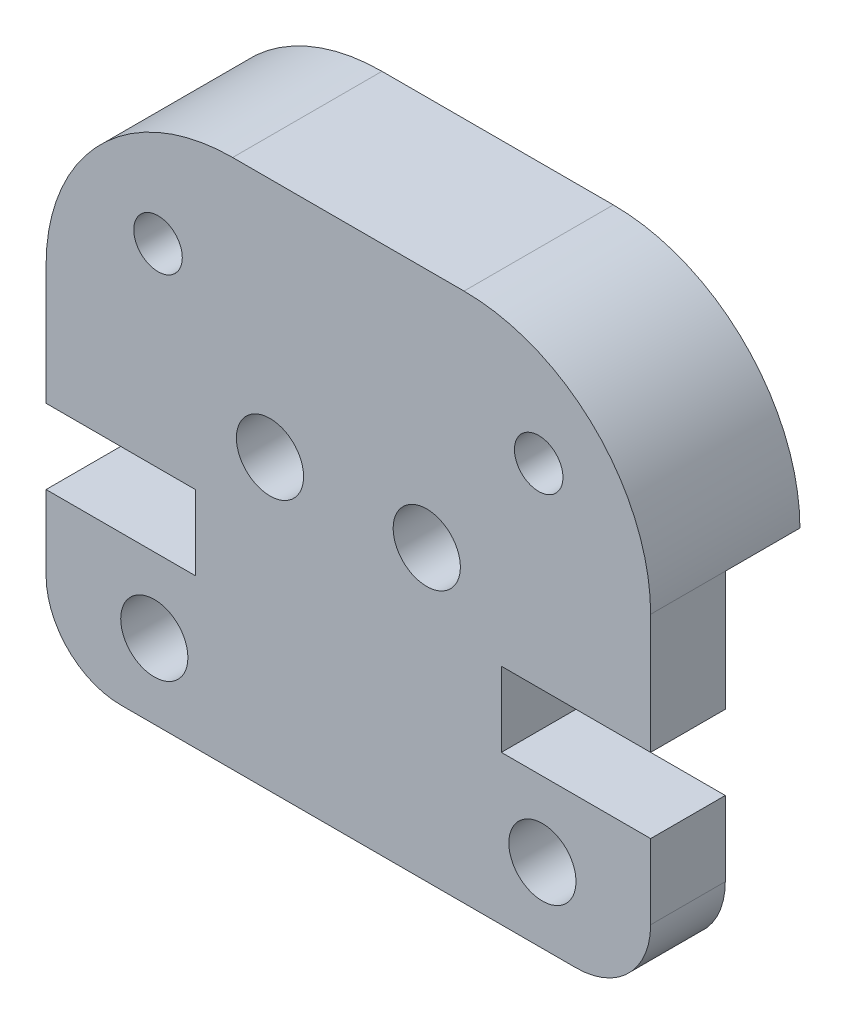
from build123d import *

# Parameters (mm, degrees)
SKETCH1_R           = 0.9
SKETCH1_R_2         = 0.65
BOSS_EXTRUDE1_DEPTH = 4
SKETCH2_W           = 16.2
SKETCH2_H           = 9.205
CUT_EXTRUDE1_DEPTH  = 2


with BuildPart() as part:
    # Sketch1 → Boss-Extrude1 (new body)
    with BuildSketch(Plane.XY):
        with BuildLine():
            Line((12.2, 4), (16.2, 4))
            Line((16.2, 4), (16.2, 2))
            ThreePointArc((16.2, 2), (15.614213562, 0.585786438), (14.2, 0))
            Line((14.2, 0), (2, 0))
            ThreePointArc((2, 0), (0.585786438, 0.585786438), (0, 2))
            Line((0, 2), (0, 4))
            Line((0, 4), (4, 4))
            Line((4, 4), (4, 6))
            Line((4, 6), (0, 6))
            Line((0, 6), (0, 9.205))
            ThreePointArc((0, 9.205), (1.464466094, 12.740533906), (5, 14.205))
            Line((5, 14.205), (11.2, 14.205))
            ThreePointArc((11.2, 14.205), (14.735533906, 12.740533906), (16.2, 9.205))
            Line((16.2, 9.205), (16.2, 6))
            Line((16.2, 6), (12.2, 6))
            Line((12.2, 6), (12.2, 4))
        make_face()
        with Locations((13.3, 2)):
            Circle(SKETCH1_R, mode=Mode.SUBTRACT)
        with Locations((13.2, 11.205)):
            Circle(SKETCH1_R_2, mode=Mode.SUBTRACT)
        with Locations((10.2, 7.75)):
            Circle(SKETCH1_R, mode=Mode.SUBTRACT)
        with Locations((6, 7.75)):
            Circle(SKETCH1_R, mode=Mode.SUBTRACT)
        with Locations((3, 11.205)):
            Circle(SKETCH1_R_2, mode=Mode.SUBTRACT)
        with Locations((2.9, 2)):
            Circle(SKETCH1_R, mode=Mode.SUBTRACT)
    extrude(amount=BOSS_EXTRUDE1_DEPTH)

    # Sketch2 → Cut-Extrude1 (cut)
    with BuildSketch(Plane(origin=(0, 0, 0), x_dir=(-1, 0, 0), z_dir=(0, 0, -1))):
        with Locations((-8.1, 4.6025)):
            Rectangle(SKETCH2_W, SKETCH2_H)
    extrude(amount=-CUT_EXTRUDE1_DEPTH, mode=Mode.SUBTRACT)


solid = part.part
